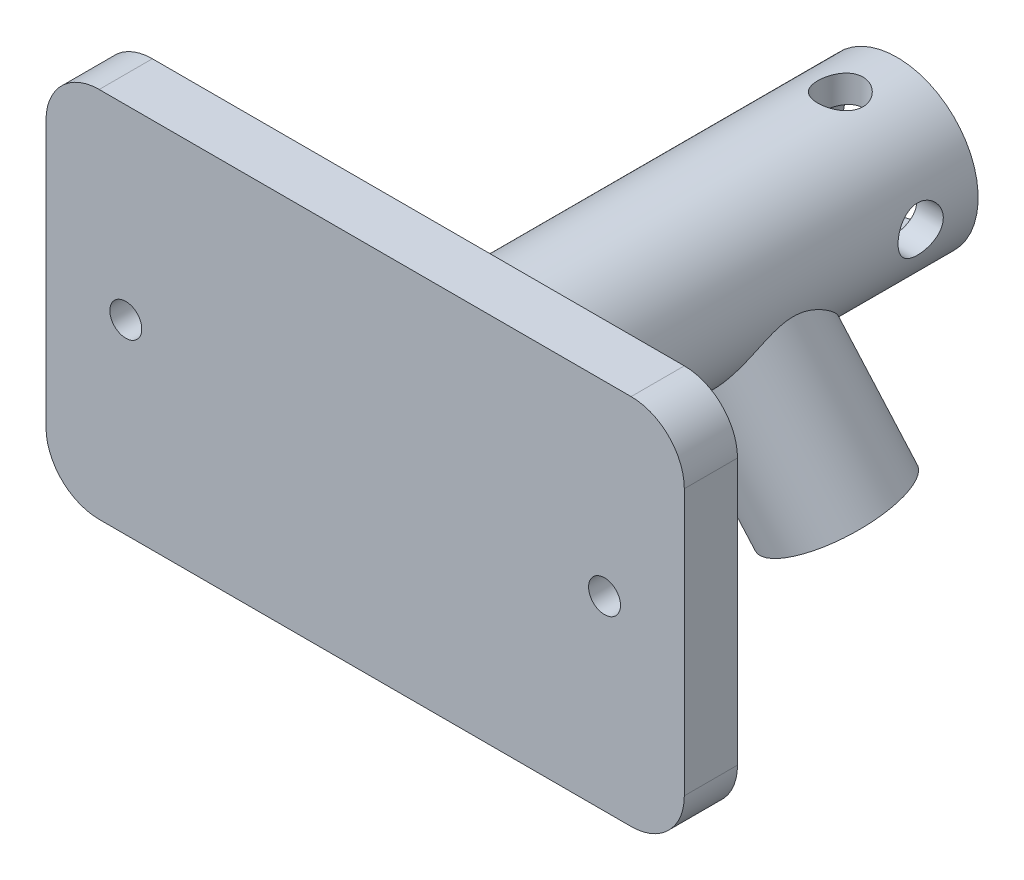
from build123d import *

# Parameters (mm, degrees)
SKETCH1_W                = 120
SKETCH1_H                = 70
SKETCH1_R                = 3
BOSS_EXTRUDE1_DEPTH      = 10
SKETCH2_R                = 15.24
SKETCH2_R_2              = 10.16
BOSS_EXTRUDE2_DEPTH      = 90
BOSS_EXTRUDE4_DEPTH      = 27
BOSS_EXTRUDE4_DEPTH_BACK = 20
SKETCH4_R                = 12.2
SKETCH4_R_2              = 10.2
SKETCH6_R                = 4.25
CUT_EXTRUDE1_DEPTH       = 58
SKETCH7_R                = 4.25
CUT_EXTRUDE2_DEPTH       = 81
FILLET1_R                = 10
SKETCH8_R                = 10.211266942
CUT_EXTRUDE3_DEPTH       = 81


with BuildPart() as part:
    # Sketch1 → Boss-Extrude1 (new body)
    with BuildSketch(Plane.XY):
        Rectangle(SKETCH1_W, SKETCH1_H)
        with Locations((-45, 0)):
            Circle(SKETCH1_R, mode=Mode.SUBTRACT)
        with Locations((45, 0)):
            Circle(SKETCH1_R, mode=Mode.SUBTRACT)
    extrude(amount=BOSS_EXTRUDE1_DEPTH)

    # Sketch2 → Boss-Extrude2 (add)
    with BuildSketch(Plane(origin=(0, 0, 0), x_dir=(-1, 0, 0), z_dir=(0, 0, -1))):
        Circle(SKETCH2_R)
        Circle(SKETCH2_R_2, mode=Mode.SUBTRACT)
    extrude(amount=BOSS_EXTRUDE2_DEPTH)

    # Sketch4 → Boss-Extrude4 (add, two sides: drawn at the far end of the back side and taken through both)
    with BuildSketch(Plane(origin=(12.998571072, -24.340292843, -4.528818833), x_dir=(0.8853889944012755, 0.45700753148549944, 0.08503202196013275), z_dir=(-0.46485086704565615, 0.870450003260969, 0.16195821445632522)).offset(-BOSS_EXTRUDE4_DEPTH_BACK)):
        with Locations((-4.468384796, 53.00095998)):
            Circle(SKETCH4_R)
        with Locations((-4.468384796, 53.00095998)):
            Circle(SKETCH4_R_2, mode=Mode.SUBTRACT)
    extrude(amount=BOSS_EXTRUDE4_DEPTH + BOSS_EXTRUDE4_DEPTH_BACK)

    # Sketch6 → Cut-Extrude1 (cut)
    with BuildSketch(Plane(origin=(0, 35, 0), x_dir=(1, 0, 0), z_dir=(0, 1, 0))):
        with Locations((0, 79.330798524)):
            Circle(SKETCH6_R)
    extrude(amount=-CUT_EXTRUDE1_DEPTH, mode=Mode.SUBTRACT)

    # Sketch7 → Cut-Extrude2 (cut)
    with BuildSketch(Plane(origin=(60, 0, 0), x_dir=(0, 0, -1), z_dir=(1, 0, 0))):
        with Locations((79.196792396, 0)):
            Circle(SKETCH7_R)
    extrude(amount=-CUT_EXTRUDE2_DEPTH, mode=Mode.SUBTRACT)

    # Fillet1
    fillet1_edges = [part.edges().sort_by_distance(p)[0] for p in [
        (60, -35, 5),
        (-60, -35, 5),
        (-60, 35, 5),
        (60, 35, 5),
    ]]
    fillet(fillet1_edges, radius=FILLET1_R)

    # Sketch8 → Cut-Extrude3 (cut)
    with BuildSketch(Plane(origin=(0, 0, -90), x_dir=(-1, 0, 0), z_dir=(0, 0, -1))):
        Circle(SKETCH8_R)
    extrude(amount=-CUT_EXTRUDE3_DEPTH, mode=Mode.SUBTRACT)


solid = part.part
